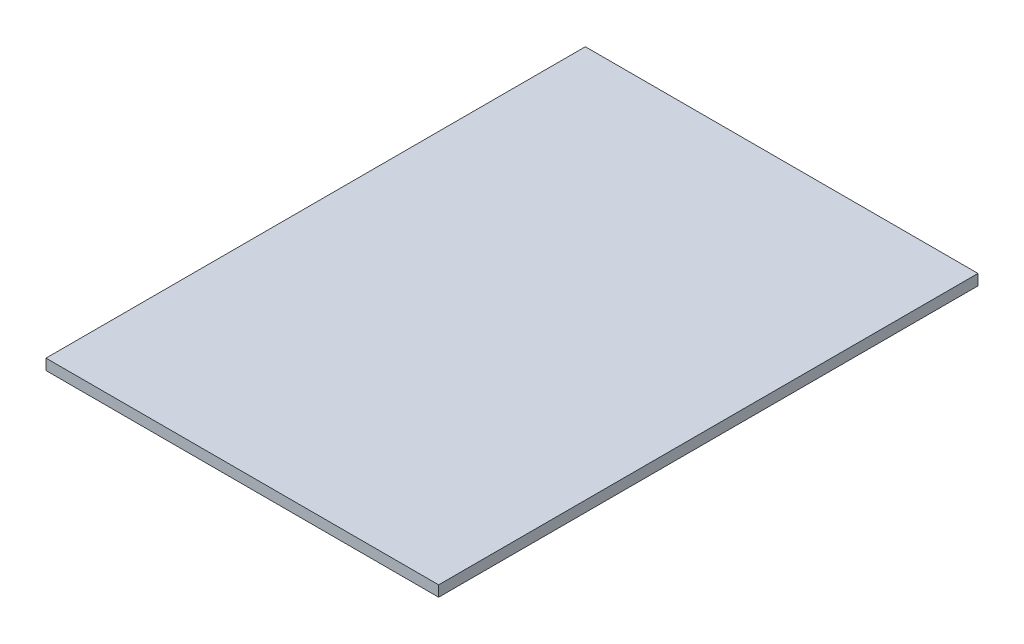
from build123d import *

# Parameters (mm, degrees)
SKETCH1_W           = 3.64
SKETCH1_H           = 5
BOSS_EXTRUDE1_DEPTH = 0.1


with BuildPart() as part:
    # Sketch1 → Boss-Extrude1 (new body)
    with BuildSketch(Plane(origin=(0, 0, 0), x_dir=(1, 0, 0), z_dir=(0, 1, 0))):
        Rectangle(SKETCH1_W, SKETCH1_H)
    extrude(amount=BOSS_EXTRUDE1_DEPTH)


solid = part.part
